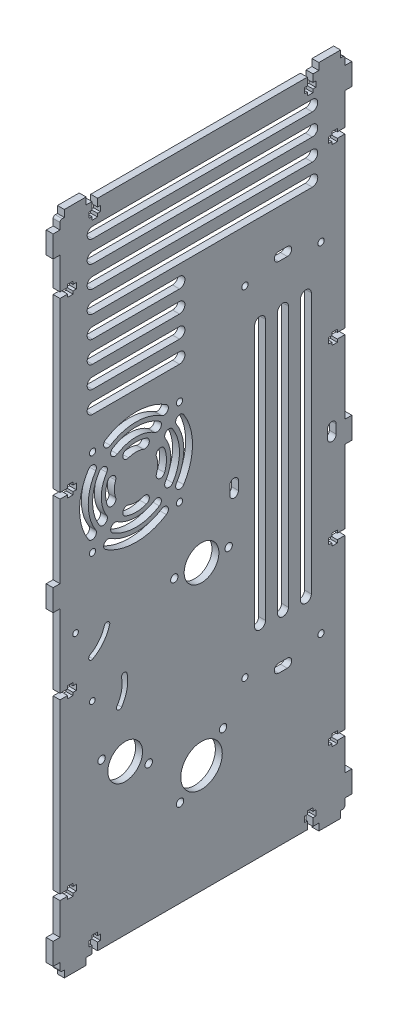
from build123d import *

# Parameters (mm, degrees)
SKETCH1_W                                    = 131.144223413
SKETCH1_H                                    = 300
TRANSMISSION_DEPTH                           = 1.5875
SKETCH9_R                                    = 7.9875
SKETCH9_R_2                                  = 9.55
BEARINGHOLES_DEPTH                           = 2.5875
BEARINGHOLES_DEPTH_BACK                      = 2.5875
BEARINGCOVERHOLES_D                          = 3.4
TENSIONERSKETCH_R                            = 1.3
TENSIONER_DEPTH                              = 2.5875
TENSIONER_DEPTH_BACK                         = 2.5875
M2_5CLEARANCEHOLES_FOR_FAN_D                 = 2.9
CUT_EXTRUDE1_START                           = -4.175
CUT_EXTRUDE1_DEPTH                           = 5.175
CIRPATTERN1_COUNT                            = 4
CUT_EXTRUDE2_DEPTH                           = 2.5875
CUT_EXTRUDE2_DEPTH_BACK                      = 2.5875
M2_5_CLEARANCE_HOLE1_D                       = 2.9
SKETCH25_W                                   = 3.175
SKETCH25_H                                   = 10
BOSS_EXTRUDE1_DEPTH                          = 3.175
CUT_EXTRUDE3_START                           = -4.175
SKETCH26_W                                   = 7.5
SKETCH26_H                                   = 2.6
SKETCH26_W_2                                 = 2.5
SKETCH26_H_2                                 = 5.2
CUT_EXTRUDE3_DEPTH                           = 5.175
LPATTERN1_COUNT                              = 4
LPATTERN1_PITCH                              = 80
MIRROR1_START                                = -4.175
MIRROR1_COPY_1_SKETCH_W                      = 7.5
MIRROR1_COPY_1_SKETCH_H                      = 2.6
MIRROR1_COPY_1_SKETCH_W_2                    = 2.5
MIRROR1_COPY_1_SKETCH_H_2                    = 5.2
MIRROR1_COPY_1_DEPTH                         = 5.175
MIRROR1_COPY_2_SKETCH_W                      = 7.5
MIRROR1_COPY_2_SKETCH_H                      = 2.6
MIRROR1_COPY_2_SKETCH_W_2                    = 2.5
MIRROR1_COPY_2_SKETCH_H_2                    = 5.2
MIRROR1_COPY_2_DEPTH                         = 5.175
MIRROR1_COPY_3_SKETCH_W                      = 7.5
MIRROR1_COPY_3_SKETCH_H                      = 2.6
MIRROR1_COPY_3_SKETCH_W_2                    = 2.5
MIRROR1_COPY_3_SKETCH_H_2                    = 5.2
MIRROR1_COPY_3_DEPTH                         = 5.175
CUT_EXTRUDE4_DEPTH                           = 10
CUT_EXTRUDE5_DEPTH                           = 10
LPATTERN2_COUNT                              = 4
LPATTERN2_PITCH                              = 10
CUT_EXTRUDE6_DEPTH                           = 10
LPATTERN3_COUNT                              = 4
LPATTERN3_PITCH                              = 10
SKETCH29_W                                   = 10
SKETCH29_H                                   = 3.175
BOSS_EXTRUDE2_DEPTH                          = 3.175
CUT_EXTRUDE7_START                           = -4.175
SKETCH30_W                                   = 2.6
SKETCH30_H                                   = 7.5
SKETCH30_W_2                                 = 5.2
SKETCH30_H_2                                 = 2.5
CUT_EXTRUDE7_DEPTH                           = 5.175
MIRROR2_AT_THE_SECOND_PLANE_COPY_1_SKETC_W   = 10
MIRROR2_AT_THE_SECOND_PLANE_COPY_1_SKETC_H   = 3.175
MIRROR2_AT_THE_SECOND_PLANE_COPY_1_DEPTH     = 3.175
MIRROR2_START                                = -4.175
MIRROR2_AT_THE_SECOND_PLANE_COPY_2_SKETC_W   = 2.6
MIRROR2_AT_THE_SECOND_PLANE_COPY_2_SKETC_H   = 7.5
MIRROR2_AT_THE_SECOND_PLANE_COPY_2_SKETC_W_2 = 5.2
MIRROR2_AT_THE_SECOND_PLANE_COPY_2_SKETC_H_2 = 2.5
MIRROR2_AT_THE_SECOND_PLANE_COPY_2_DEPTH     = 5.175
FILLET1_R                                    = 1


with BuildPart() as part:
    # Sketch1 → Transmission (new body, symmetric)
    with BuildSketch(Plane(origin=(0, 0, 0), x_dir=(0, 0, -1), z_dir=(1, 0, 0))):
        with Locations((0.427888293, 19.206230873)):
            Rectangle(SKETCH1_W, SKETCH1_H)
    extrude(amount=TRANSMISSION_DEPTH, both=True)

    # Sketch9 → BearingHoles (cut, two sides)
    with BuildSketch(Plane(origin=(0, 0, 0), x_dir=(0, 0, -1), z_dir=(1, 0, 0))) as bearingholes_sk:
        with Locations((-35.144223413, -61.691843551)):
            Circle(SKETCH9_R)
        with Locations((0, -80.793769127)):
            Circle(SKETCH9_R_2)
        Circle(SKETCH9_R)
    extrude(amount=BEARINGHOLES_DEPTH, mode=Mode.SUBTRACT)
    extrude(bearingholes_sk.sketch, amount=-BEARINGHOLES_DEPTH_BACK, mode=Mode.SUBTRACT)

    # BearingCoverHoles (through all)
    with Locations(Plane(origin=(1.5875, 0, 0), x_dir=(0, 0, -1), z_dir=(1, 0, 0))):
        with Locations((-46.005463475, -55.504480274), (-24.282983351, -67.879206828), (9.899494937, -70.89427419), (-9.899494937, -90.693264063), (-12.5, 0), (12.5, 0)):
            Hole(BEARINGCOVERHOLES_D / 2)

    # TensionerSketch → Tensioner (cut, two sides)
    with BuildSketch(Plane(origin=(0, 0, 0), x_dir=(0, 0, -1), z_dir=(1, 0, 0))) as tensioner_sk:
        with Locations((-57.971968062, 0.915433776)):
            Circle(TENSIONERSKETCH_R)
        with Locations((-50.256862686, -30.005053497)):
            Circle(TENSIONERSKETCH_R)
        with BuildLine():
            ThreePointArc((-49.988471073, -13.295610374), (-45.157847443, -9.15870702), (-42.278057518, -3.488107052))
            ThreePointArc((-42.278057518, -3.488107052), (-43.178516452, -1.885242832), (-44.781380672, -2.785701767))
            ThreePointArc((-44.781380672, -2.785701767), (-47.201817603, -7.551788856), (-51.261912311, -11.028818056))
            ThreePointArc((-51.261912311, -11.028818056), (-51.758587851, -12.798934834), (-49.988471073, -13.295610374))
        make_face()
        with BuildLine():
            ThreePointArc((-36.772676499, -39.162931136), (-34.294531007, -33.305654556), (-34.246505814, -26.945891385))
            ThreePointArc((-34.246505814, -26.945891385), (-35.767387696, -25.912974012), (-36.80030507, -27.433855894))
            ThreePointArc((-36.80030507, -27.433855894), (-36.840669802, -32.779178314), (-38.923528284, -37.702165378))
            ThreePointArc((-38.923528284, -37.702165378), (-38.578485271, -39.507974149), (-36.772676499, -39.162931136))
        make_face()
    extrude(amount=TENSIONER_DEPTH, mode=Mode.SUBTRACT)
    extrude(tensioner_sk.sketch, amount=-TENSIONER_DEPTH_BACK, mode=Mode.SUBTRACT)

    # M2.5ClearanceHoles for Fan (through all)
    with Locations(Plane(origin=(1.5875, 0, 0), x_dir=(0, 0, -1), z_dir=(1, 0, 0))):
        with Locations((-50.144223413, 29.206230873), (-50.144223413, 69.206230873), (-10.144223413, 29.206230873), (-10.144223413, 69.206230873)):
            Hole(M2_5CLEARANCEHOLES_FOR_FAN_D / 2)

    # Sketch21 → Cut-Extrude1 (cut)
    with BuildSketch(Plane(origin=(1.5875, 0, 0), x_dir=(0, 0, -1), z_dir=(1, 0, 0)).offset(CUT_EXTRUDE1_START)):
        with BuildLine():
            ThreePointArc((-16.174433596, 71.134408465), (-30.144223413, 75.206230873), (-44.11401323, 71.134408465))
            ThreePointArc((-44.11401323, 71.134408465), (-44.726196905, 68.373026356), (-41.964814797, 67.760842681))
            ThreePointArc((-41.964814797, 67.760842681), (-30.144223413, 71.206230873), (-18.323632029, 67.760842681))
            ThreePointArc((-18.323632029, 67.760842681), (-15.562249921, 68.373026356), (-16.174433596, 71.134408465))
        make_face()
        with BuildLine():
            ThreePointArc((-19.398231246, 66.07405979), (-30.144223413, 69.206230873), (-40.89021558, 66.07405979))
            ThreePointArc((-40.89021558, 66.07405979), (-41.502399255, 63.312677681), (-38.741017146, 62.700494006))
            ThreePointArc((-38.741017146, 62.700494006), (-30.144223413, 65.206230873), (-21.547429679, 62.700494006))
            ThreePointArc((-21.547429679, 62.700494006), (-18.786047571, 63.312677681), (-19.398231246, 66.07405979))
        make_face()
        with BuildLine():
            ThreePointArc((-25.355941406, 62.361927564), (-30.144223413, 63.206230873), (-34.93250542, 62.361927564))
            ThreePointArc((-34.93250542, 62.361927564), (-36.127850374, 59.798502036), (-33.564424846, 58.603157081))
            ThreePointArc((-33.564424846, 58.603157081), (-30.144223413, 59.206230873), (-26.72402198, 58.603157081))
            ThreePointArc((-26.72402198, 58.603157081), (-24.160596451, 59.798502036), (-25.355941406, 62.361927564))
        make_face()
    cut_extrude1 = extrude(amount=CUT_EXTRUDE1_DEPTH, mode=Mode.SUBTRACT)

    # CirPattern1: Cut-Extrude1 ×4 about axis
    cirpattern1_axis = Axis((0, 49.206230873, 30.144223413), (1, 0, 0))
    for i in range(1, CIRPATTERN1_COUNT):
        add(cut_extrude1.rotate(cirpattern1_axis, i * 360 / CIRPATTERN1_COUNT), mode=Mode.SUBTRACT)

    # Sketch22 → Cut-Extrude2 (cut, two sides)
    with BuildSketch(Plane(origin=(0, 0, 0), x_dir=(0, 0, -1), z_dir=(1, 0, 0))) as cut_extrude2_sk:
        with BuildLine():
            Line((17, 24.256230873), (17, 20.256230873))
            ThreePointArc((17, 20.256230873), (15, 18.256230873), (13, 20.256230873))
            Line((13, 20.256230873), (13, 24.256230873))
            ThreePointArc((13, 24.256230873), (15, 26.256230873), (17, 24.256230873))
        make_face()
        with BuildLine():
            Line((62, 24.256230873), (62, 20.256230873))
            ThreePointArc((62, 20.256230873), (60, 18.256230873), (58, 20.256230873))
            Line((58, 20.256230873), (58, 24.256230873))
            ThreePointArc((58, 24.256230873), (60, 26.256230873), (62, 24.256230873))
        make_face()
        with BuildLine():
            Line((35.5, 106.306230873), (39.5, 106.306230873))
            ThreePointArc((39.5, 106.306230873), (41.5, 104.306230873), (39.5, 102.306230873))
            Line((39.5, 102.306230873), (35.5, 102.306230873))
            ThreePointArc((35.5, 102.306230873), (33.5, 104.306230873), (35.5, 106.306230873))
        make_face()
        with BuildLine():
            Line((35.5, -57.793769127), (39.5, -57.793769127))
            ThreePointArc((39.5, -57.793769127), (41.5, -59.793769127), (39.5, -61.793769127))
            Line((39.5, -61.793769127), (35.5, -61.793769127))
            ThreePointArc((35.5, -61.793769127), (33.5, -59.793769127), (35.5, -57.793769127))
        make_face()
    extrude(amount=CUT_EXTRUDE2_DEPTH, mode=Mode.SUBTRACT)
    extrude(cut_extrude2_sk.sketch, amount=-CUT_EXTRUDE2_DEPTH_BACK, mode=Mode.SUBTRACT)

    # M2.5 Clearance Hole1 (through all)
    with Locations(Plane(origin=(1.5875, 0, 0), x_dir=(0, 0, -1), z_dir=(1, 0, 0))):
        with Locations((20, 100.306230873), (55, 100.306230873), (55, -55.793769127), (20, -55.793769127)):
            Hole(M2_5_CLEARANCE_HOLE1_D / 2)

    # Sketch25 → Boss-Extrude1 (add)
    with BuildSketch(Plane(origin=(1.5875, 0, 0), x_dir=(0, 0, -1), z_dir=(1, 0, 0))):
        with Locations((-66.731723413, 160.206230873)):
            Rectangle(SKETCH25_W, SKETCH25_H)
        with Locations((-66.731723413, 19.206230873)):
            Rectangle(SKETCH25_W, SKETCH25_H)
        with Locations((-66.731723413, -121.793769127)):
            Rectangle(SKETCH25_W, SKETCH25_H)
    boss_extrude1 = extrude(amount=-BOSS_EXTRUDE1_DEPTH)

    # Sketch26 → Cut-Extrude3 (cut)
    with BuildSketch(Plane(origin=(1.5875, 0, 0), x_dir=(0, 0, -1), z_dir=(1, 0, 0)).offset(CUT_EXTRUDE3_START)):
        with Locations((-61.394223413, 139.206230873)):
            Rectangle(SKETCH26_W, SKETCH26_H)
        with Locations((-60.394223413, 139.206230873)):
            Rectangle(SKETCH26_W_2, SKETCH26_H_2)
    cut_extrude3 = extrude(amount=CUT_EXTRUDE3_DEPTH, mode=Mode.SUBTRACT)

    # LPattern1: Cut-Extrude3 ×4
    with Locations(*[(0, -i * LPATTERN1_PITCH, 0) for i in range(1, LPATTERN1_COUNT)]):
        add(cut_extrude3, mode=Mode.SUBTRACT)

    # Mirror1: Boss-Extrude1, Cut-Extrude3 across plane
    add(boss_extrude1.mirror(Plane(origin=(0, 0, -0.427888294), x_dir=(1, 0, 0), z_dir=(0, 0, -1))))
    add(cut_extrude3.mirror(Plane(origin=(0, 0, -0.427888294), x_dir=(1, 0, 0), z_dir=(0, 0, -1))), mode=Mode.SUBTRACT)

    # Mirror1 copy 1 sketch → Mirror1 copy 1 (cut)
    with BuildSketch(Plane(origin=(1.5875, -80, -0.855776587), x_dir=(0, 0, 1), z_dir=(1, 0, 0)).offset(MIRROR1_START)):
        with Locations((-61.394223413, -139.206230873)):
            Rectangle(MIRROR1_COPY_1_SKETCH_W, MIRROR1_COPY_1_SKETCH_H)
        with Locations((-60.394223413, -139.206230873)):
            Rectangle(MIRROR1_COPY_1_SKETCH_W_2, MIRROR1_COPY_1_SKETCH_H_2)
    extrude(amount=MIRROR1_COPY_1_DEPTH, mode=Mode.SUBTRACT)

    # Mirror1 copy 2 sketch → Mirror1 copy 2 (cut)
    with BuildSketch(Plane(origin=(1.5875, -160, -0.855776587), x_dir=(0, 0, 1), z_dir=(1, 0, 0)).offset(MIRROR1_START)):
        with Locations((-61.394223413, -139.206230873)):
            Rectangle(MIRROR1_COPY_2_SKETCH_W, MIRROR1_COPY_2_SKETCH_H)
        with Locations((-60.394223413, -139.206230873)):
            Rectangle(MIRROR1_COPY_2_SKETCH_W_2, MIRROR1_COPY_2_SKETCH_H_2)
    extrude(amount=MIRROR1_COPY_2_DEPTH, mode=Mode.SUBTRACT)

    # Mirror1 copy 3 sketch → Mirror1 copy 3 (cut)
    with BuildSketch(Plane(origin=(1.5875, -240, -0.855776587), x_dir=(0, 0, 1), z_dir=(1, 0, 0)).offset(MIRROR1_START)):
        with Locations((-61.394223413, -139.206230873)):
            Rectangle(MIRROR1_COPY_3_SKETCH_W, MIRROR1_COPY_3_SKETCH_H)
        with Locations((-60.394223413, -139.206230873)):
            Rectangle(MIRROR1_COPY_3_SKETCH_W_2, MIRROR1_COPY_3_SKETCH_H_2)
    extrude(amount=MIRROR1_COPY_3_DEPTH, mode=Mode.SUBTRACT)

    # Sketch28 → Cut-Extrude4 (cut)
    with BuildSketch(Plane(origin=(1.5875, 0, 0), x_dir=(0, 0, -1), z_dir=(1, 0, 0))):
        with BuildLine():
            Line((45.555735297, 82.256230873), (45.555735297, -37.743769127))
            ThreePointArc((45.555735297, -37.743769127), (48.055735297, -40.243769127), (50.555735297, -37.743769127))
            Line((50.555735297, -37.743769127), (50.555735297, 82.256230873))
            ThreePointArc((50.555735297, 82.256230873), (48.055735297, 84.756230873), (45.555735297, 82.256230873))
        make_face()
        with BuildLine():
            Line((35, 82.256230873), (35, -37.743769127))
            ThreePointArc((35, -37.743769127), (37.5, -40.243769127), (40, -37.743769127))
            Line((40, -37.743769127), (40, 82.256230873))
            ThreePointArc((40, 82.256230873), (37.5, 84.756230873), (35, 82.256230873))
        make_face()
        with BuildLine():
            Line((24.444264703, 82.256230873), (24.444264703, -37.743769127))
            ThreePointArc((24.444264703, -37.743769127), (26.944264703, -40.243769127), (29.444264703, -37.743769127))
            Line((29.444264703, -37.743769127), (29.444264703, 82.256230873))
            ThreePointArc((29.444264703, 82.256230873), (26.944264703, 84.756230873), (24.444264703, 82.256230873))
        make_face()
    extrude(amount=-CUT_EXTRUDE4_DEPTH, mode=Mode.SUBTRACT)

    # Sketch28_4 → Cut-Extrude5 (cut)
    with BuildSketch(Plane(origin=(1.5875, 0, 0), x_dir=(0, 0, -1), z_dir=(1, 0, 0))):
        with BuildLine():
            Line((-50.144223413, 84.206230873), (-10.144223413, 84.206230873))
            ThreePointArc((-10.144223413, 84.206230873), (-7.644223413, 86.706230873), (-10.144223413, 89.206230873))
            Line((-10.144223413, 89.206230873), (-50.144223413, 89.206230873))
            ThreePointArc((-50.144223413, 89.206230873), (-52.644223413, 86.706230873), (-50.144223413, 84.206230873))
        make_face()
    cut_extrude5 = extrude(amount=-CUT_EXTRUDE5_DEPTH, mode=Mode.SUBTRACT)

    # LPattern2: Cut-Extrude5 ×4
    with Locations(*[(0, i * LPATTERN2_PITCH, 0) for i in range(1, LPATTERN2_COUNT)]):
        add(cut_extrude5, mode=Mode.SUBTRACT)

    # Sketch28_5 → Cut-Extrude6 (cut)
    with BuildSketch(Plane(origin=(1.5875, 0, 0), x_dir=(0, 0, -1), z_dir=(1, 0, 0))):
        with BuildLine():
            Line((-50.144223413, 154.206230873), (51, 154.206230873))
            ThreePointArc((51, 154.206230873), (53.5, 156.706230873), (51, 159.206230873))
            Line((51, 159.206230873), (-50.144223413, 159.206230873))
            ThreePointArc((-50.144223413, 159.206230873), (-52.644223413, 156.706230873), (-50.144223413, 154.206230873))
        make_face()
    cut_extrude6 = extrude(amount=-CUT_EXTRUDE6_DEPTH, mode=Mode.SUBTRACT)

    # LPattern3: Cut-Extrude6 ×4
    with Locations(*[(0, -i * LPATTERN3_PITCH, 0) for i in range(1, LPATTERN3_COUNT)]):
        add(cut_extrude6, mode=Mode.SUBTRACT)

    # Sketch29 → Boss-Extrude2 (add)
    with BuildSketch(Plane(origin=(1.5875, 0, 0), x_dir=(0, 0, -1), z_dir=(1, 0, 0))):
        with Locations((-58.144223413, 170.793730873)):
            Rectangle(SKETCH29_W, SKETCH29_H)
    boss_extrude2 = extrude(amount=-BOSS_EXTRUDE2_DEPTH)

    # Sketch30 → Cut-Extrude7 (cut)
    with BuildSketch(Plane(origin=(1.5875, 0, 0), x_dir=(0, 0, -1), z_dir=(1, 0, 0)).offset(CUT_EXTRUDE7_START)):
        with Locations((-49.144223413, 165.456230873)):
            Rectangle(SKETCH30_W, SKETCH30_H)
        with Locations((-49.144223413, 164.456230873)):
            Rectangle(SKETCH30_W_2, SKETCH30_H_2)
    cut_extrude7 = extrude(amount=CUT_EXTRUDE7_DEPTH, mode=Mode.SUBTRACT)

    # Mirror2: Boss-Extrude2, Cut-Extrude7 across plane
    add(boss_extrude2.mirror(Plane.ZX.offset(19.206230873)))
    add(cut_extrude7.mirror(Plane.ZX.offset(19.206230873)), mode=Mode.SUBTRACT)

    # Mirror2 at the second plane: Cut-Extrude7, Boss-Extrude2 across plane
    add(cut_extrude7.mirror(Plane(origin=(0, 0, -0.427888294), x_dir=(1, 0, 0), z_dir=(0, 0, -1))), mode=Mode.SUBTRACT)
    add(boss_extrude2.mirror(Plane(origin=(0, 0, -0.427888294), x_dir=(1, 0, 0), z_dir=(0, 0, -1))))

    # Mirror2 at the second plane copy 1 sketc → Mirror2 at the second plane copy 1 (add)
    with BuildSketch(Plane(origin=(1.5875, 38.412461747, -0.855776587), x_dir=(0, 0, 1), z_dir=(1, 0, 0))):
        with Locations((-58.144223413, 170.793730873)):
            Rectangle(MIRROR2_AT_THE_SECOND_PLANE_COPY_1_SKETC_W, MIRROR2_AT_THE_SECOND_PLANE_COPY_1_SKETC_H)
    extrude(amount=-MIRROR2_AT_THE_SECOND_PLANE_COPY_1_DEPTH)

    # Mirror2 at the second plane copy 2 sketc → Mirror2 at the second plane copy 2 (cut)
    with BuildSketch(Plane(origin=(1.5875, 38.412461747, -0.855776587), x_dir=(0, 0, 1), z_dir=(1, 0, 0)).offset(MIRROR2_START)):
        with Locations((-49.144223413, 165.456230873)):
            Rectangle(MIRROR2_AT_THE_SECOND_PLANE_COPY_2_SKETC_W, MIRROR2_AT_THE_SECOND_PLANE_COPY_2_SKETC_H)
        with Locations((-49.144223413, 164.456230873)):
            Rectangle(MIRROR2_AT_THE_SECOND_PLANE_COPY_2_SKETC_W_2, MIRROR2_AT_THE_SECOND_PLANE_COPY_2_SKETC_H_2)
    extrude(amount=MIRROR2_AT_THE_SECOND_PLANE_COPY_2_DEPTH, mode=Mode.SUBTRACT)

    # Fillet1
    fillet1_edges = [part.edges().sort_by_distance(p)[0] for p in [
        (0, 169.206230873, 65.144223413),
        (0, 169.206230873, -66),
        (0, -130.793769127, -66),
        (0, -130.793769127, 65.144223413),
    ]]
    fillet(fillet1_edges, radius=FILLET1_R)


solid = part.part
